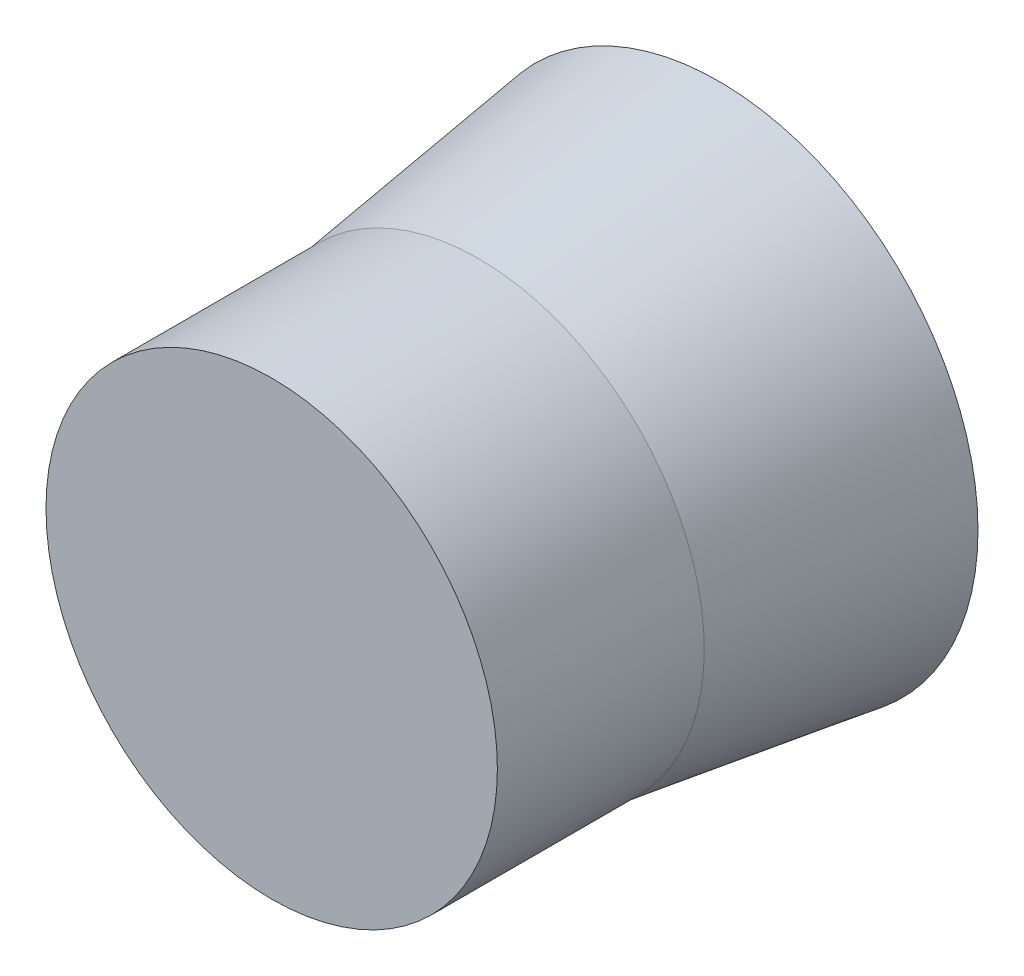
from build123d import *


with BuildPart() as part:
    # Sketch2 → Revolve1 (revolve)
    with BuildSketch(Plane(origin=(0, 0, 0), x_dir=(0, 0, -1), z_dir=(1, 0, 0))):
        Polygon((0, 0), (232, 0), (232, 34), (208, 44.61538461), (208, 120.61538461), (96.257951206, 104.999999995), (0, 104.999999995), align=None)
    revolve(axis=Axis((0, 0, 0), (0, 0, -1)))


solid = part.part
